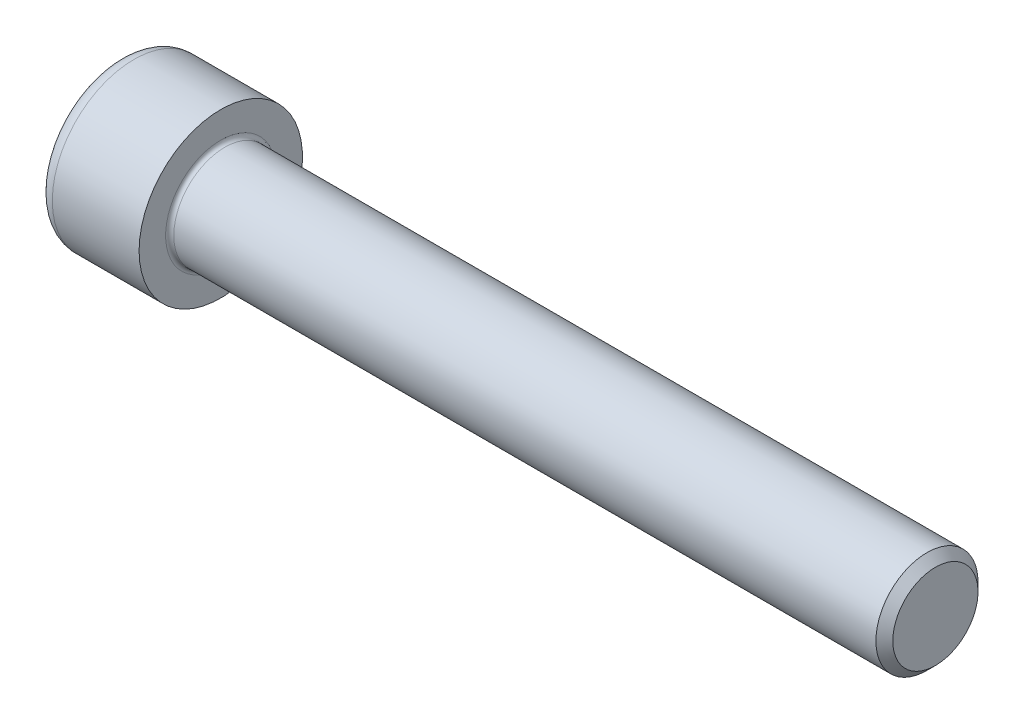
from build123d import *

# Parameters (mm, degrees)
FILLET1_R   = 0.4
FILLET2_R   = 1.5
HEX_2_DEPTH = 5


with BuildPart() as part:
    # BodySke → Base-Revolve (revolve)
    with BuildSketch(Plane.XY):
        Polygon((0, 0), (0, 8), (10, 8), (10, 5), (79.172, 5), (80, 4.172), (80, 0), align=None)
    revolve(axis=Axis((-31.75, 0, 0), (1, 0, 0)))

    # Fillet1
    fillet1_edges = [part.edges().sort_by_distance(p)[0] for p in [
        (10, -5, 0),
    ]]
    fillet(fillet1_edges, radius=FILLET1_R)

    # Fillet2
    fillet2_edges = [part.edges().sort_by_distance(p)[0] for p in [
        (0, -8, 0),
    ]]
    fillet(fillet2_edges, radius=FILLET2_R)

    # Sketch2 → Hex-PreBroach (revolve, cut)
    with BuildSketch(Plane.XY):
        Polygon((0, 4.0575), (5, 4.0575), (7.342598717, 0), (0, 0), align=None)
    revolve(axis=Axis((0, 0, 0), (1, 0, 0)), mode=Mode.SUBTRACT)

    # Sketch3 → Hex 2 (cut)
    with BuildSketch(Plane(origin=(0, 0, 0), x_dir=(0, 0.5, 0.866025404), z_dir=(-1, 0, 0))):
        Polygon((2.342598717, 4.0575), (-2.342598717, 4.0575), (-4.685197434, 0), (-2.342598717, -4.0575), (2.342598717, -4.0575), (4.685197434, 0), align=None)
    extrude(amount=-HEX_2_DEPTH, mode=Mode.SUBTRACT)


solid = part.part
